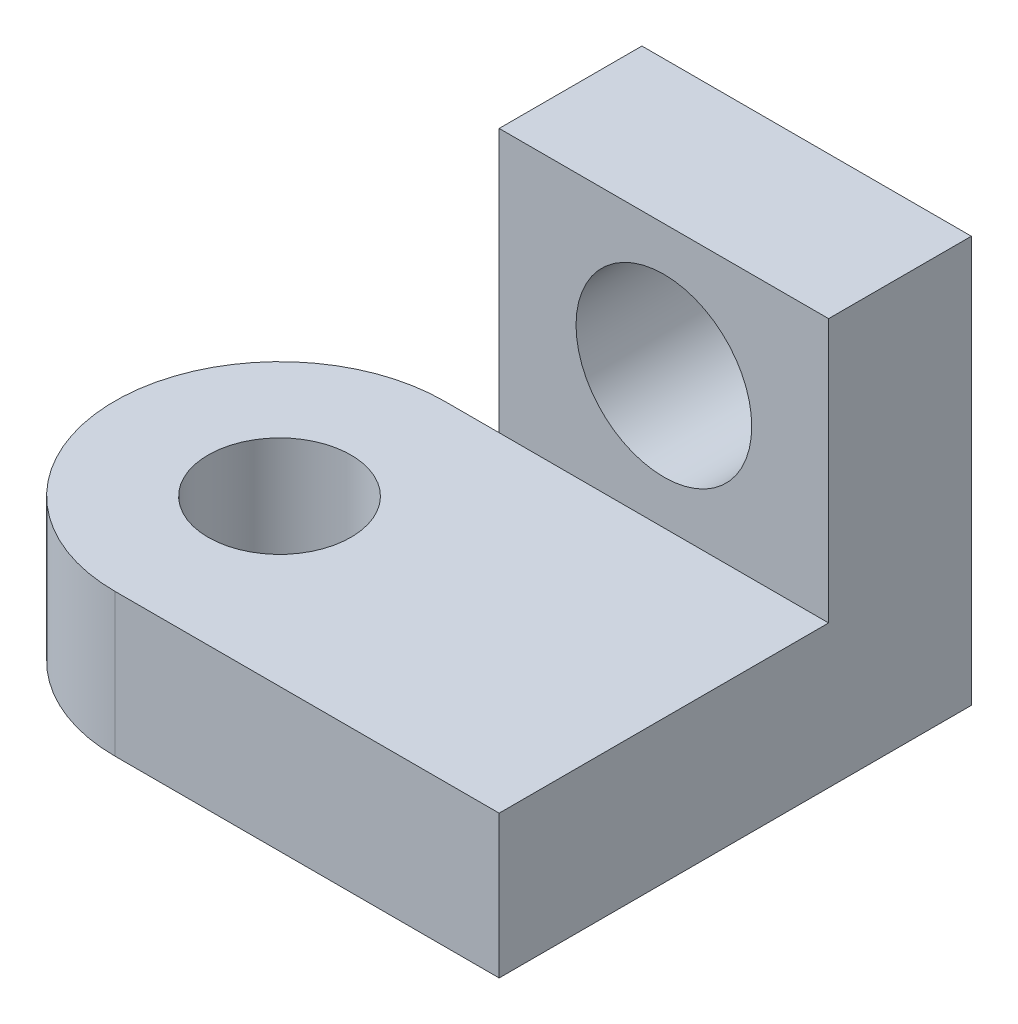
from build123d import *

# Parameters (mm, degrees)
SKETCH1_R           = 6.5
BOSS_EXTRUDE1_DEPTH = 13
SKETCH2_W           = 30
SKETCH2_H           = 13
BOSS_EXTRUDE2_DEPTH = 37
SKETCH3_R           = 8
CUT_EXTRUDE1_DEPTH  = 43


with BuildPart() as part:
    # Sketch1 → Boss-Extrude1 (new body)
    with BuildSketch(Plane(origin=(0, 0, 0), x_dir=(1, 0, 0), z_dir=(0, 1, 0))):
        with BuildLine():
            Line((0, 0), (-35, 0))
            ThreePointArc((-35, 0), (-50, 15), (-35, 30))
            Line((-35, 30), (0, 30))
            Line((0, 30), (0, 0))
        make_face()
        with Locations((-35, 15)):
            Circle(SKETCH1_R, mode=Mode.SUBTRACT)
    extrude(amount=BOSS_EXTRUDE1_DEPTH)

    # Sketch2 → Boss-Extrude2 (add)
    with BuildSketch(Plane(origin=(0, 0, 0), x_dir=(1, 0, 0), z_dir=(0, 1, 0))):
        with Locations((-15, 36.5)):
            Rectangle(SKETCH2_W, SKETCH2_H)
    extrude(amount=BOSS_EXTRUDE2_DEPTH)

    # Sketch3 → Cut-Extrude1 (cut)
    with BuildSketch(Plane.XY):
        with Locations((-15, 25)):
            Circle(SKETCH3_R)
    extrude(amount=-CUT_EXTRUDE1_DEPTH, mode=Mode.SUBTRACT)


solid = part.part
